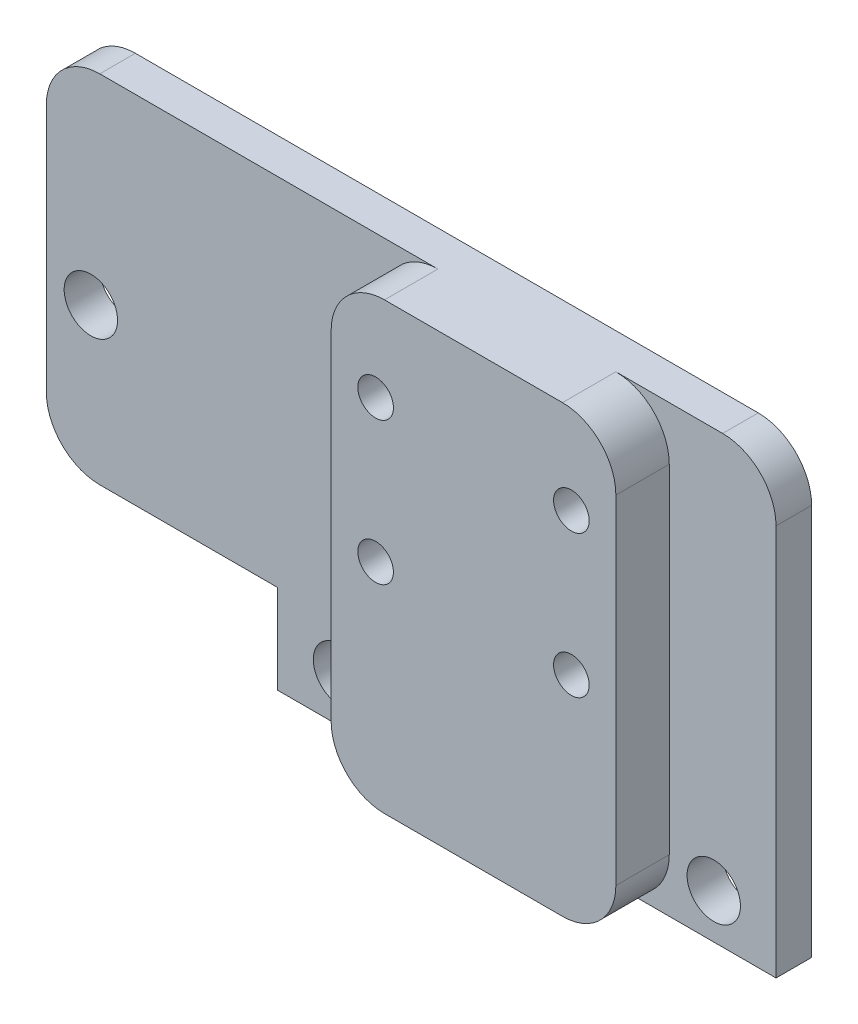
from build123d import *

# Parameters (mm, degrees)
BOSS_EXTRU_1_DEPTH      = 2
ESQUISSE2_W             = 16
ESQUISSE2_H             = 25
BOSS_EXTRU_2_DEPTH      = 3
ENL_V_MAT_EXTRU_1_REACH = 4
ESQUISSE3_R             = 1.5
ENL_V_MAT_EXTRU_2_REACH = 7
ESQUISSE4_R             = 1
ENL_V_MAT_EXTRU_3_REACH = 4
ESQUISSE5_W             = 13
ESQUISSE5_H             = 20
CONG_1_R                = 3


with BuildPart() as part:
    # Esquisse1 → Boss.-Extru.1 (new body)
    with BuildSketch(Plane.XY):
        Polygon((-27, 25), (27, 25), (27, 5), (14, 5), (14, 0), (-14, 0), (-14, 5), (-27, 5), align=None)
    extrude(amount=BOSS_EXTRU_1_DEPTH)

    # Esquisse2 → Boss.-Extru.2 (add)
    with BuildSketch(Plane.XY.offset(2)):
        with Locations((0, 12.5)):
            Rectangle(ESQUISSE2_W, ESQUISSE2_H)
    extrude(amount=BOSS_EXTRU_2_DEPTH)

    # Esquisse3 → Enlèv. mat.-Extru.1 (cut, up to next)
    with BuildSketch(Plane.XY.offset(2), mode=Mode.PRIVATE) as enl_v_mat_extru_1_sk1:
        with Locations((-24.5, 13.5)):
            Circle(ESQUISSE3_R)
    enl_v_mat_extru_1_tool1 = extrude(enl_v_mat_extru_1_sk1.sketch, amount=-ENL_V_MAT_EXTRU_1_REACH, mode=Mode.PRIVATE) & part.part
    add(enl_v_mat_extru_1_tool1.solids().sort_by_distance((-24.5, 13.5, 2))[0], mode=Mode.SUBTRACT)
    # Esquisse3 → Enlèv. mat.-Extru.1 (cut, up to next)
    with BuildSketch(Plane.XY.offset(2), mode=Mode.PRIVATE) as enl_v_mat_extru_1_sk2:
        with Locations((-10.5, 2.5)):
            Circle(ESQUISSE3_R)
    enl_v_mat_extru_1_tool2 = extrude(enl_v_mat_extru_1_sk2.sketch, amount=-ENL_V_MAT_EXTRU_1_REACH, mode=Mode.PRIVATE) & part.part
    add(enl_v_mat_extru_1_tool2.solids().sort_by_distance((-10.5, 2.5, 2))[0], mode=Mode.SUBTRACT)
    # Esquisse3 → Enlèv. mat.-Extru.1 (cut, up to next)
    with BuildSketch(Plane.XY.offset(2), mode=Mode.PRIVATE) as enl_v_mat_extru_1_sk3:
        with Locations((10.5, 2.5)):
            Circle(ESQUISSE3_R)
    enl_v_mat_extru_1_tool3 = extrude(enl_v_mat_extru_1_sk3.sketch, amount=-ENL_V_MAT_EXTRU_1_REACH, mode=Mode.PRIVATE) & part.part
    add(enl_v_mat_extru_1_tool3.solids().sort_by_distance((10.5, 2.5, 2))[0], mode=Mode.SUBTRACT)

    # Esquisse4 → Enlèv. mat.-Extru.2 (cut, up to next)
    with BuildSketch(Plane.XY.offset(5), mode=Mode.PRIVATE) as enl_v_mat_extru_2_sk1:
        with Locations((-5.5, 20)):
            Circle(ESQUISSE4_R)
    enl_v_mat_extru_2_tool1 = extrude(enl_v_mat_extru_2_sk1.sketch, amount=-ENL_V_MAT_EXTRU_2_REACH, mode=Mode.PRIVATE) & part.part
    add(enl_v_mat_extru_2_tool1.solids().sort_by_distance((-5.5, 20, 5))[0], mode=Mode.SUBTRACT)
    # Esquisse4 → Enlèv. mat.-Extru.2 (cut, up to next)
    with BuildSketch(Plane.XY.offset(5), mode=Mode.PRIVATE) as enl_v_mat_extru_2_sk2:
        with Locations((-5.5, 12)):
            Circle(ESQUISSE4_R)
    enl_v_mat_extru_2_tool2 = extrude(enl_v_mat_extru_2_sk2.sketch, amount=-ENL_V_MAT_EXTRU_2_REACH, mode=Mode.PRIVATE) & part.part
    add(enl_v_mat_extru_2_tool2.solids().sort_by_distance((-5.5, 12, 5))[0], mode=Mode.SUBTRACT)
    # Esquisse4 → Enlèv. mat.-Extru.2 (cut, up to next)
    with BuildSketch(Plane.XY.offset(5), mode=Mode.PRIVATE) as enl_v_mat_extru_2_sk3:
        with Locations((5.5, 12)):
            Circle(ESQUISSE4_R)
    enl_v_mat_extru_2_tool3 = extrude(enl_v_mat_extru_2_sk3.sketch, amount=-ENL_V_MAT_EXTRU_2_REACH, mode=Mode.PRIVATE) & part.part
    add(enl_v_mat_extru_2_tool3.solids().sort_by_distance((5.5, 12, 5))[0], mode=Mode.SUBTRACT)
    # Esquisse4 → Enlèv. mat.-Extru.2 (cut, up to next)
    with BuildSketch(Plane.XY.offset(5), mode=Mode.PRIVATE) as enl_v_mat_extru_2_sk4:
        with Locations((5.5, 20)):
            Circle(ESQUISSE4_R)
    enl_v_mat_extru_2_tool4 = extrude(enl_v_mat_extru_2_sk4.sketch, amount=-ENL_V_MAT_EXTRU_2_REACH, mode=Mode.PRIVATE) & part.part
    add(enl_v_mat_extru_2_tool4.solids().sort_by_distance((5.5, 20, 5))[0], mode=Mode.SUBTRACT)

    # Esquisse5 → Enlèv. mat.-Extru.3 (cut, up to next)
    with BuildSketch(Plane.XY.offset(2), mode=Mode.PRIVATE) as enl_v_mat_extru_3_sk1:
        with Locations((20.5, 15)):
            Rectangle(ESQUISSE5_W, ESQUISSE5_H)
    enl_v_mat_extru_3_tool1 = extrude(enl_v_mat_extru_3_sk1.sketch, amount=-ENL_V_MAT_EXTRU_3_REACH, mode=Mode.PRIVATE) & part.part
    add(enl_v_mat_extru_3_tool1.solids().sort_by_distance((20.5, 15, 2))[0], mode=Mode.SUBTRACT)

    # Congé1
    cong_1_edges = [part.edges().sort_by_distance(p)[0] for p in [
        (8, 0, 3.5),
        (-8, 0, 3.5),
        (8, 25, 3.5),
        (-8, 25, 3.5),
        (-27, 5, 1),
        (-27, 25, 1),
        (14, 25, 1),
    ]]
    fillet(cong_1_edges, radius=CONG_1_R)


solid = part.part
